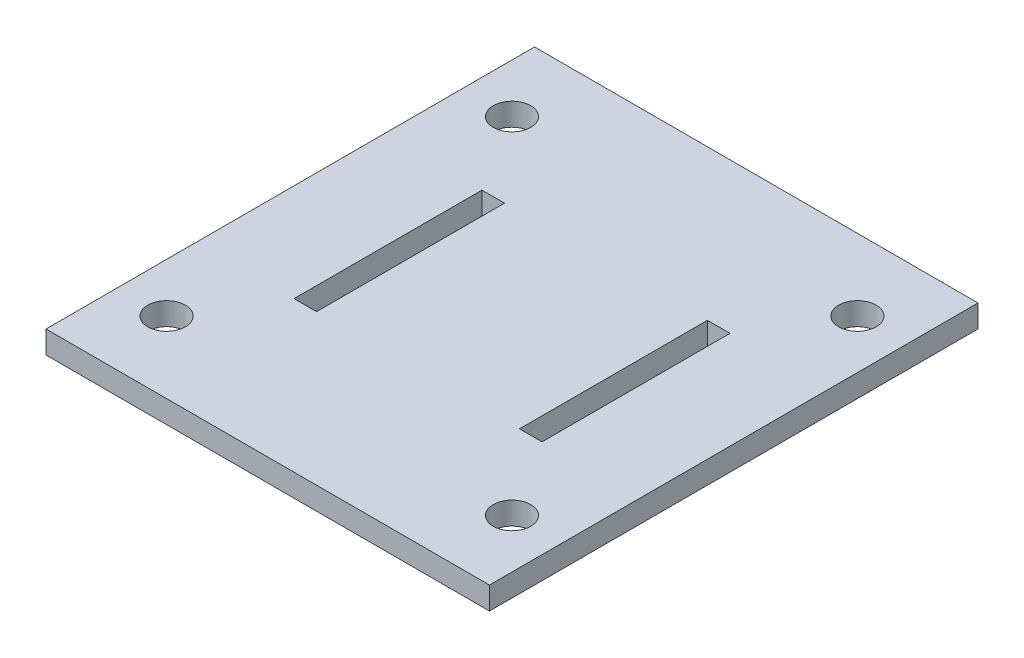
from build123d import *

# Parameters (mm, degrees)
SKETCH1_R           = 2.5
SKETCH1_W           = 3
SKETCH1_H           = 25
BOSS_EXTRUDE1_DEPTH = 3


with BuildPart() as part:
    # Sketch1 → Boss-Extrude1 (new body)
    with BuildSketch(Plane(origin=(0, 0, 0), x_dir=(1, 0, 0), z_dir=(0, 1, 0))):
        Polygon((-29.5, 32.5), (-29.5, 12.5), (-29.5, -12.5), (-29.5, -32.5), (29.5, -32.5), (29.5, -12.5), (29.5, 12.5), (29.5, 32.5), align=None)
        with Locations((-22.980970389, -22.980970389)):
            Circle(SKETCH1_R, mode=Mode.SUBTRACT)
        with Locations((22.980970389, -22.980970389)):
            Circle(SKETCH1_R, mode=Mode.SUBTRACT)
        with Locations((-15, 0)):
            Rectangle(SKETCH1_W, SKETCH1_H, mode=Mode.SUBTRACT)
        with Locations((-22.980970389, 22.980970389)):
            Circle(SKETCH1_R, mode=Mode.SUBTRACT)
        with Locations((15, 0)):
            Rectangle(SKETCH1_W, SKETCH1_H, mode=Mode.SUBTRACT)
        with Locations((22.980970389, 22.980970389)):
            Circle(SKETCH1_R, mode=Mode.SUBTRACT)
    extrude(amount=BOSS_EXTRUDE1_DEPTH)


solid = part.part
